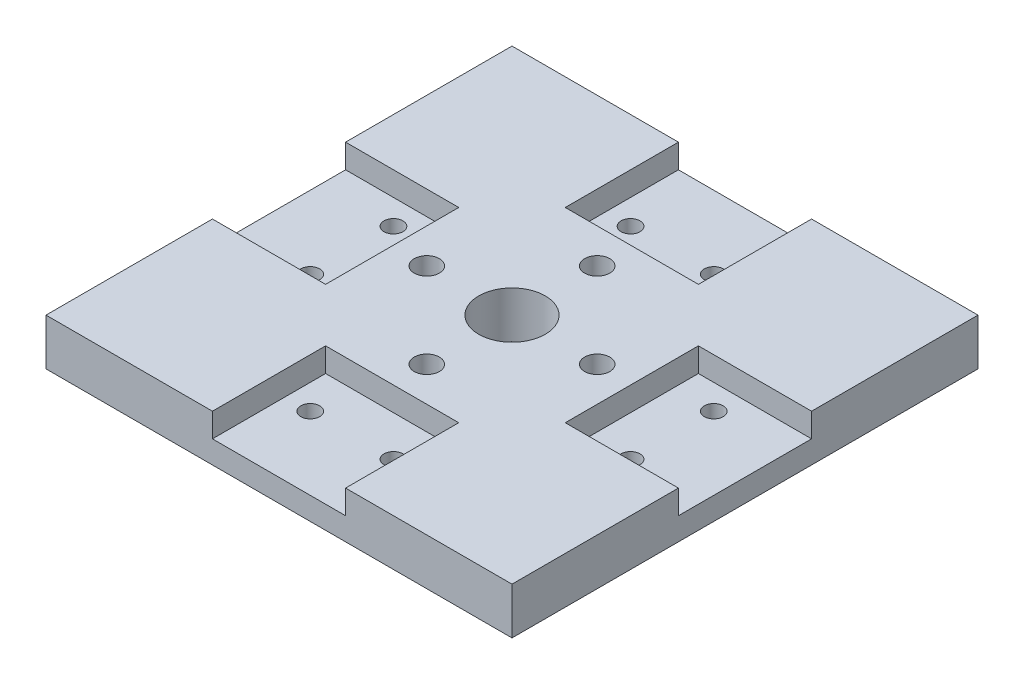
from build123d import *

# Parameters (mm, degrees)
SKETCH1_W           = 88.9
SKETCH1_H           = 88.9
BOSS_EXTRUDE1_DEPTH = 8.89
SKETCH2_W           = 25.4
SKETCH2_H           = 21.59
SKETCH2_W_2         = 21.59
SKETCH2_H_2         = 25.4
CUT_EXTRUDE1_DEPTH  = 4.572
SKETCH3_R           = 2.400000026
CUT_EXTRUDE2_DEPTH  = 9.89
SKETCH4_R           = 1.8034
CUT_EXTRUDE3_DEPTH  = 5.318
SKETCH5_R           = 6.35
CUT_EXTRUDE4_DEPTH  = 9.89


with BuildPart() as part:
    # Sketch1 → Boss-Extrude1 (new body)
    with BuildSketch(Plane(origin=(0, 0, 0), x_dir=(1, 0, 0), z_dir=(0, 1, 0))):
        with Locations((44.45, 44.45)):
            Rectangle(SKETCH1_W, SKETCH1_H)
    extrude(amount=BOSS_EXTRUDE1_DEPTH)

    # Sketch2 → Cut-Extrude1 (cut)
    with BuildSketch(Plane(origin=(0, 8.89, 0), x_dir=(1, 0, 0), z_dir=(0, 1, 0))):
        with Locations((44.45, 78.105)):
            Rectangle(SKETCH2_W, SKETCH2_H)
        with Locations((10.795, 44.45)):
            Rectangle(SKETCH2_W_2, SKETCH2_H_2)
        with Locations((44.45, 10.795)):
            Rectangle(SKETCH2_W, SKETCH2_H)
        with Locations((78.105, 44.45)):
            Rectangle(SKETCH2_W_2, SKETCH2_H_2)
    extrude(amount=-CUT_EXTRUDE1_DEPTH, mode=Mode.SUBTRACT)

    # Sketch3 → Cut-Extrude2 (cut, through all)
    with BuildSketch(Plane(origin=(0, 8.89, 0), x_dir=(1, 0, 0), z_dir=(0, 1, 0))):
        with Locations((28.194, 44.45)):
            Circle(SKETCH3_R)
        with Locations((44.45, 60.706)):
            Circle(SKETCH3_R)
        with Locations((60.706, 44.45)):
            Circle(SKETCH3_R)
        with Locations((44.45, 28.194)):
            Circle(SKETCH3_R)
    extrude(amount=-CUT_EXTRUDE2_DEPTH, mode=Mode.SUBTRACT)

    # Sketch4 → Cut-Extrude3 (cut, through all)
    with BuildSketch(Plane(origin=(0, 4.318, 0), x_dir=(1, 0, 0), z_dir=(0, 1, 0))):
        with Locations((75.0062, 52.3875)):
            Circle(SKETCH4_R)
        with Locations((75.0062, 36.5125)):
            Circle(SKETCH4_R)
        with Locations((52.3875, 75.0062)):
            Circle(SKETCH4_R)
        with Locations((36.5125, 75.0062)):
            Circle(SKETCH4_R)
        with Locations((13.8938, 52.3875)):
            Circle(SKETCH4_R)
        with Locations((13.8938, 36.5125)):
            Circle(SKETCH4_R)
        with Locations((36.5125, 13.8938)):
            Circle(SKETCH4_R)
        with Locations((52.3875, 13.8938)):
            Circle(SKETCH4_R)
    extrude(amount=-CUT_EXTRUDE3_DEPTH, mode=Mode.SUBTRACT)

    # Sketch5 → Cut-Extrude4 (cut, through all)
    with BuildSketch(Plane(origin=(0, 8.89, 0), x_dir=(1, 0, 0), z_dir=(0, 1, 0))):
        with Locations((44.45, 44.45)):
            Circle(SKETCH5_R)
    extrude(amount=-CUT_EXTRUDE4_DEPTH, mode=Mode.SUBTRACT)


solid = part.part
